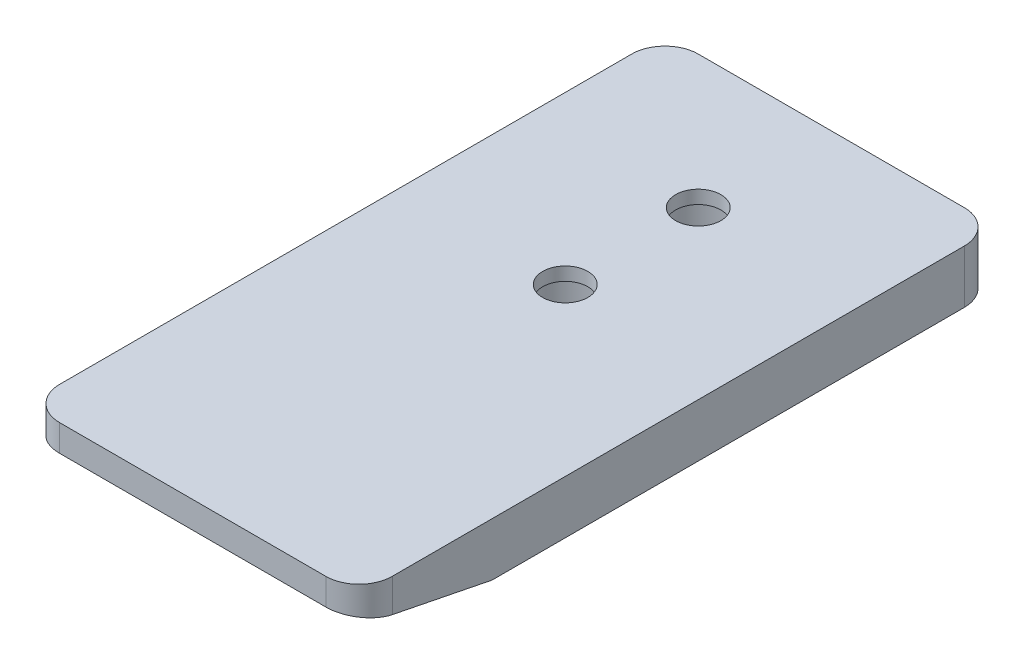
from build123d import *

# Parameters (mm, degrees)
SKETCH1_W                      = 25
SKETCH1_H                      = 30
BOSS_EXTRUDE1_DEPTH            = 4
CBORE_FOR_M3_SHCS2_D           = 3.4
CBORE_FOR_M3_SHCS2_CBORE_D     = 6.5
CBORE_FOR_M3_SHCS2_CBORE_DEPTH = 3
SKETCH5_W                      = 25
SKETCH5_H                      = 4
BOSS_EXTRUDE2_DEPTH            = 18
CHAMFER1_SIZE                  = 10
CHAMFER1_SIZE2                 = 2
FILLET1_R                      = 2.5


with BuildPart() as part:
    # Sketch1 → Boss-Extrude1 (new body)
    with BuildSketch(Plane(origin=(0, 0, 0), x_dir=(1, 0, 0), z_dir=(0, 1, 0))):
        with Locations((12.5, 15)):
            Rectangle(SKETCH1_W, SKETCH1_H)
    extrude(amount=BOSS_EXTRUDE1_DEPTH)

    # CBORE for M3 SHCS2 (through all)
    with Locations(Plane(origin=(0, 0, 0), x_dir=(-1, 0, 0), z_dir=(0, -1, 0))):
        with Locations((-12.5, 20), (-12.5, 10)):
            CounterBoreHole(CBORE_FOR_M3_SHCS2_D / 2, CBORE_FOR_M3_SHCS2_CBORE_D / 2, CBORE_FOR_M3_SHCS2_CBORE_DEPTH)

    # Sketch5 → Boss-Extrude2 (add)
    with BuildSketch(Plane.XY):
        with Locations((12.5, 2)):
            Rectangle(SKETCH5_W, SKETCH5_H)
    extrude(amount=BOSS_EXTRUDE2_DEPTH)

    # Chamfer1
    chamfer1_edges = [part.edges().sort_by_distance(p)[0] for p in [
        (12.5, 0, 18),
    ]]
    chamfer1_side = [part.faces().sort_by_distance(p)[0] for p in [
        (12.5, 0, -5.473114445),
    ]]
    chamfer(chamfer1_edges, length=CHAMFER1_SIZE, length2=CHAMFER1_SIZE2, reference=chamfer1_side[0])

    # Fillet1
    fillet1_edges = [part.edges().sort_by_distance(p)[0] for p in [
        (0, 3, 18),
        (25, 3, 18),
        (0, 2, -30),
        (25, 2, -30),
    ]]
    fillet(fillet1_edges, radius=FILLET1_R)


solid = part.part
